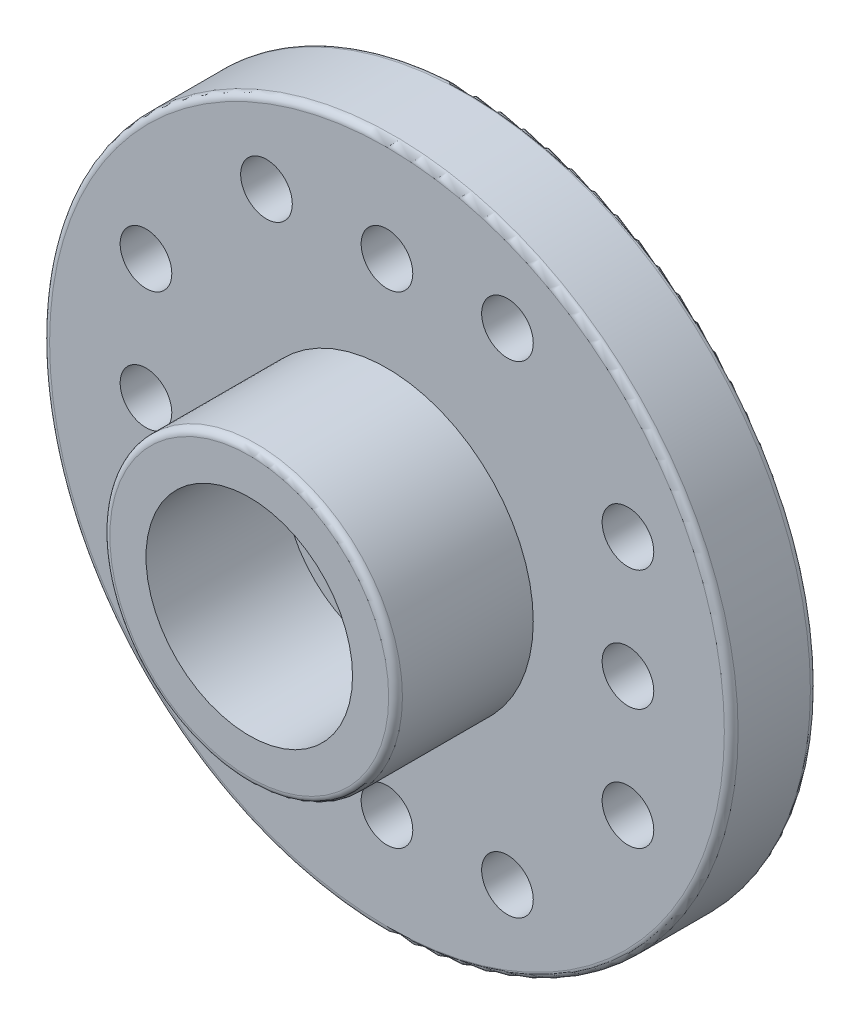
from build123d import *

# Parameters (mm, degrees)
SKETCH1_R           = 10
SKETCH1_R_2         = 0.75
SKETCH1_R_3         = 1.5
BOSS_EXTRUDE1_DEPTH = 2.5
SKETCH5_R           = 4.25
SKETCH5_R_2         = 3
BOSS_EXTRUDE2_DEPTH = 4
SKETCH6_R           = 4.5
CUT_EXTRUDE1_DEPTH  = 0.8
SKETCH7_R           = 3.7
SKETCH7_R_2         = 3.5
BOSS_EXTRUDE3_DEPTH = 0.8
FILLET1_R           = 0.2


with BuildPart() as part:
    # Sketch1 → Boss-Extrude1 (new body)
    with BuildSketch(Plane.XY):
        Circle(SKETCH1_R)
        with Locations((-7, 0)):
            Circle(SKETCH1_R_2, mode=Mode.SUBTRACT)
        with Locations((3.5, 7)):
            Circle(SKETCH1_R_2, mode=Mode.SUBTRACT)
        with Locations((0, 7)):
            Circle(SKETCH1_R_2, mode=Mode.SUBTRACT)
        with Locations((-3.5, 7)):
            Circle(SKETCH1_R_2, mode=Mode.SUBTRACT)
        with Locations((7, -3.5)):
            Circle(SKETCH1_R_2, mode=Mode.SUBTRACT)
        with Locations((7, 0)):
            Circle(SKETCH1_R_2, mode=Mode.SUBTRACT)
        with Locations((7, 3.5)):
            Circle(SKETCH1_R_2, mode=Mode.SUBTRACT)
        with Locations((-3.5, -7)):
            Circle(SKETCH1_R_2, mode=Mode.SUBTRACT)
        with Locations((0, -7)):
            Circle(SKETCH1_R_2, mode=Mode.SUBTRACT)
        with Locations((3.5, -7)):
            Circle(SKETCH1_R_2, mode=Mode.SUBTRACT)
        with Locations((-7, -3.5)):
            Circle(SKETCH1_R_2, mode=Mode.SUBTRACT)
        with Locations((-7, 3.5)):
            Circle(SKETCH1_R_2, mode=Mode.SUBTRACT)
        Circle(SKETCH1_R_3, mode=Mode.SUBTRACT)
    extrude(amount=BOSS_EXTRUDE1_DEPTH)

    # Sketch5 → Boss-Extrude2 (add)
    with BuildSketch(Plane.XY.offset(2.5)):
        Circle(SKETCH5_R)
        Circle(SKETCH5_R_2, mode=Mode.SUBTRACT)
    extrude(amount=BOSS_EXTRUDE2_DEPTH)

    # Sketch6 → Cut-Extrude1 (cut)
    with BuildSketch(Plane(origin=(0, 0, 0), x_dir=(-1, 0, 0), z_dir=(0, 0, -1))):
        Circle(SKETCH6_R)
    extrude(amount=-CUT_EXTRUDE1_DEPTH, mode=Mode.SUBTRACT)

    # Sketch7 → Boss-Extrude3 (add)
    with BuildSketch(Plane(origin=(0, 0, 0.8), x_dir=(-1, 0, 0), z_dir=(0, 0, -1))):
        Circle(SKETCH7_R)
        Circle(SKETCH7_R_2, mode=Mode.SUBTRACT)
    extrude(amount=BOSS_EXTRUDE3_DEPTH)

    # Fillet1
    fillet1_edges = [part.edges().sort_by_distance(p)[0] for p in [
        (-10, 0, 0),
        (-10, 0, 2.5),
        (-4.25, 0, 6.5),
        (4.5, 0, 0),
    ]]
    fillet(fillet1_edges, radius=FILLET1_R)


solid = part.part
